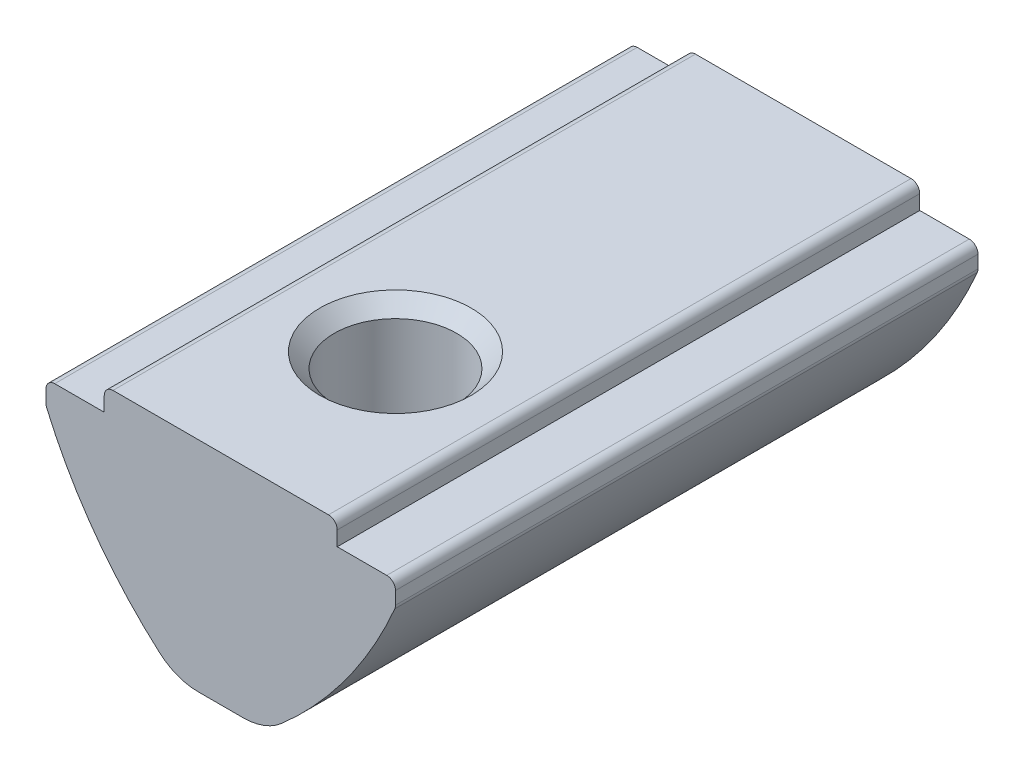
from build123d import *

# Parameters (mm, degrees)
EXTRUDE_1_DEPTH             = 10
FILLET_1_R                  = 0.3
FILLET_2_R                  = 2
HOLE_WIZARD_M51_D           = 4.2
HOLE_WIZARD_M51_CSINK_D     = 5.2
HOLE_WIZARD_M51_CSINK_ANGLE = 90


with BuildPart() as part:
    # Эскиз1 → Бобышка-Вытянуть1 (new body, symmetric)
    with BuildSketch(Plane.XY):
        with BuildLine():
            Line((-4, 0), (4, 0))
            Line((4, 0), (4, -0.8))
            Line((4, -0.8), (6, -0.8))
            Line((6, -0.8), (6, -1.6))
            ThreePointArc((6, -1.6), (4.120585945, -4.832650297), (1.5, -7.5))
            Line((1.5, -7.5), (-1.5, -7.5))
            ThreePointArc((-1.5, -7.5), (-4.120585945, -4.832650297), (-6, -1.6))
            Line((-6, -1.6), (-6, -0.8))
            Line((-6, -0.8), (-4, -0.8))
            Line((-4, -0.8), (-4, 0))
        make_face()
    extrude(amount=EXTRUDE_1_DEPTH, both=True)

    # Скругление1
    fillet_1_edges = [part.edges().sort_by_distance(p)[0] for p in [
        (6, -0.8, 0),
        (6, -1.6, 0),
        (-6, -1.6, 0),
        (-6, -0.8, 0),
        (-4, 0, 0),
        (4, 0, 0),
    ]]
    fillet(fillet_1_edges, radius=FILLET_1_R)

    # Скругление2
    fillet_2_edges = [part.edges().sort_by_distance(p)[0] for p in [
        (1.5, -7.5, 0),
        (-1.5, -7.5, 0),
    ]]
    fillet(fillet_2_edges, radius=FILLET_2_R)

    # Отверстие обработанное метчиком M51 (through all)
    with Locations(Plane(origin=(0, 0, 0), x_dir=(1, 0, 0), z_dir=(0, 1, 0))):
        with Locations((0, -4)):
            CounterSinkHole(HOLE_WIZARD_M51_D / 2, HOLE_WIZARD_M51_CSINK_D / 2, counter_sink_angle=HOLE_WIZARD_M51_CSINK_ANGLE)

    # Эскиз5 → Повернуть1 (revolve)
    with BuildSketch(Plane(origin=(0, 0, 0), x_dir=(0, 0, -1), z_dir=(1, 0, 0))):
        with BuildLine():
            Line((6, -4.3), (6, -8.3))
            ThreePointArc((6, -8.3), (4, -6.3), (6, -4.3))
        make_face()
    revolve(axis=Axis((0, -4.3, -6), (0, -1, 0)))


solid = part.part
